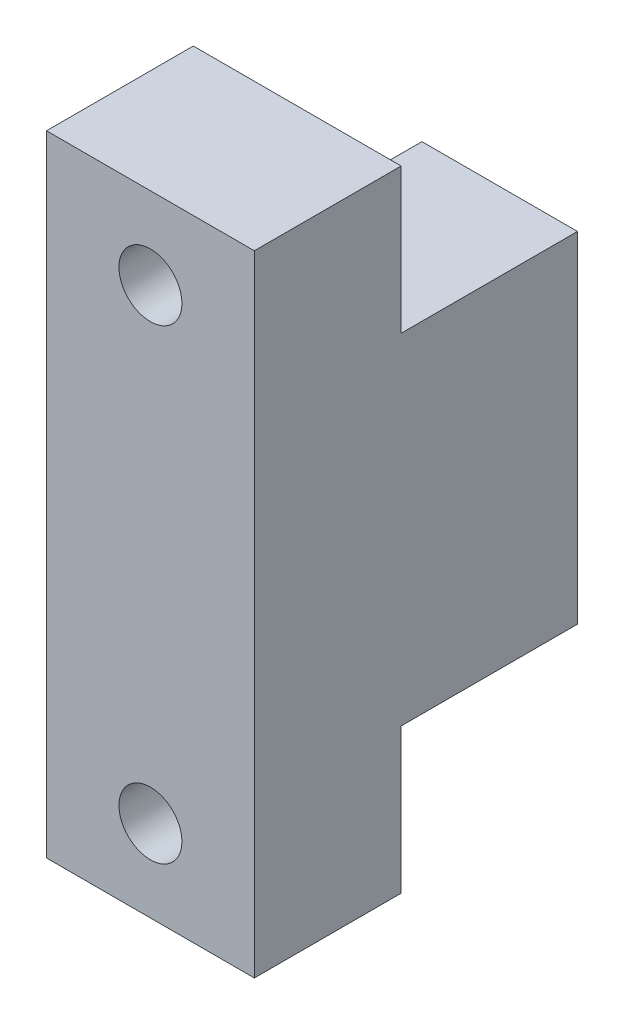
from build123d import *

# Parameters (mm, degrees)
SKETCH2_W           = 16.5
SKETCH2_H           = 50
SKETCH2_R           = 2.5
BOSS_EXTRUDE1_DEPTH = 11.655
CUT_EXTRUDE3_START  = -7
SKETCH4_R           = 4.5
CUT_EXTRUDE3_DEPTH  = 10
SKETCH6_W           = 12.35
SKETCH6_H           = 27
BOSS_EXTRUDE2_DEPTH = 6
SKETCH7_R           = 2.1
CUT_EXTRUDE4_DEPTH  = 6
CHAMFER1_SIZE       = 1
BOSS_EXTRUDE3_DEPTH = 8


with BuildPart() as part:
    # Sketch2 → Boss-Extrude1 (new body)
    with BuildSketch(Plane.XY):
        with Locations((-2.723788813, 9.906715388)):
            Rectangle(SKETCH2_W, SKETCH2_H)
        with Locations((-2.723788813, -8.593284612)):
            Circle(SKETCH2_R, mode=Mode.SUBTRACT)
        with Locations((-2.723788813, 28.406715388)):
            Circle(SKETCH2_R, mode=Mode.SUBTRACT)
    extrude(amount=BOSS_EXTRUDE1_DEPTH)

    # Sketch4 → Cut-Extrude3 (cut)
    with BuildSketch(Plane.XY.offset(11.655).offset(CUT_EXTRUDE3_START)):
        with Locations((-2.723788813, 28.406715388)):
            Circle(SKETCH4_R)
        with Locations((-2.723788813, -8.593284612)):
            Circle(SKETCH4_R)
    extrude(amount=-CUT_EXTRUDE3_DEPTH, mode=Mode.SUBTRACT)

    # Sketch6 → Boss-Extrude2 (add)
    with BuildSketch(Plane(origin=(0, 0, 0), x_dir=(-1, 0, 0), z_dir=(0, 0, -1))):
        with Locations((0.648788813, 9.906715388)):
            Rectangle(SKETCH6_W, SKETCH6_H)
    extrude(amount=BOSS_EXTRUDE2_DEPTH)

    # Sketch7 → Cut-Extrude4 (cut)
    with BuildSketch(Plane(origin=(0, 0, -6), x_dir=(-1, 0, 0), z_dir=(0, 0, -1))):
        with Locations((2.723788813, 17.906715388)):
            Circle(SKETCH7_R)
        with Locations((2.723788813, 1.906715388)):
            Circle(SKETCH7_R)
    extrude(amount=-CUT_EXTRUDE4_DEPTH, mode=Mode.SUBTRACT)

    # Chamfer1
    chamfer1_edges = [part.edges().sort_by_distance(p)[0] for p in [
        (-0.623788813, 17.906715388, -6),
        (-0.623788813, 1.906715388, -6),
    ]]
    chamfer(chamfer1_edges, length=CHAMFER1_SIZE)

    # Sketch8 → Boss-Extrude3 (add)
    with BuildSketch(Plane(origin=(0, 0, -6), x_dir=(-1, 0, 0), z_dir=(0, 0, -1))):
        with BuildLine():
            Line((6.823788813, 21.806715388), (6.823788813, 23.406715388))
            Line((6.823788813, 23.406715388), (-5.526211187, 23.406715388))
            Line((-5.526211187, 23.406715388), (-5.526211187, -3.593284612))
            Line((-5.526211187, -3.593284612), (6.823788813, -3.593284612))
            Line((6.823788813, -3.593284612), (6.823788813, -1.993284612))
            Line((6.823788813, -1.993284612), (2.723788813, -1.993284612))
            ThreePointArc((2.723788813, -1.993284612), (-0.033927633, -0.851001059), (-1.176211187, 1.906715388))
            Line((-1.176211187, 1.906715388), (-1.176211187, 17.906715388))
            ThreePointArc((-1.176211187, 17.906715388), (-0.033927633, 20.664431835), (2.723788813, 21.806715388))
            Line((2.723788813, 21.806715388), (6.823788813, 21.806715388))
        make_face()
    extrude(amount=BOSS_EXTRUDE3_DEPTH)


solid = part.part
